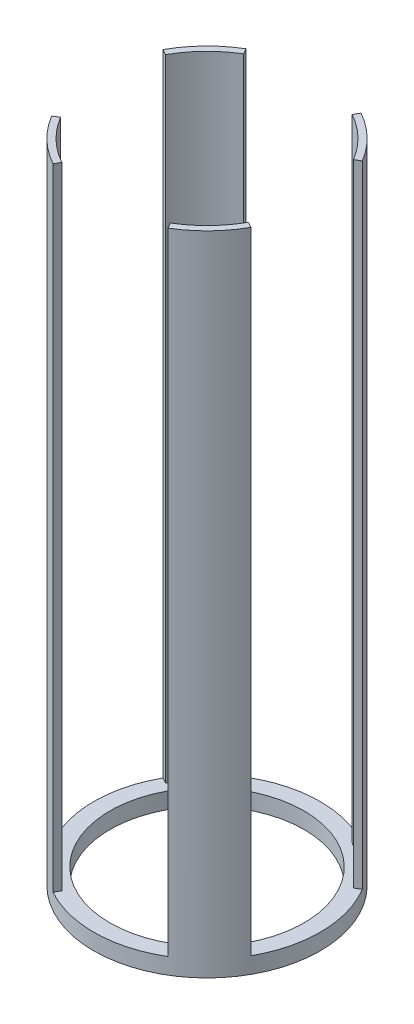
from build123d import *

# Parameters (mm, degrees)
SKETCH2_R               = 88.9
SKETCH2_R_2             = 83.82
BOSS_EXTRUDE1_DEPTH     = 254
CUT_EXTRUDE1_DEPTH      = 255
CUT_EXTRUDE1_DEPTH_BACK = 255
SKETCH4_R               = 88.9
SKETCH4_R_2             = 76.2
BOSS_EXTRUDE2_DEPTH     = 12.7


with BuildPart() as part:
    # Sketch2 → Boss-Extrude1 (new body, symmetric)
    with BuildSketch(Plane(origin=(0, 0, 0), x_dir=(1, 0, 0), z_dir=(0, 1, 0))):
        Circle(SKETCH2_R)
        Circle(SKETCH2_R_2, mode=Mode.SUBTRACT)
    extrude(amount=BOSS_EXTRUDE1_DEPTH, both=True)

    # Sketch3 → Cut-Extrude1 (cut, two sides)
    with BuildSketch(Plane(origin=(0, 0, 0), x_dir=(1, 0, 0), z_dir=(0, 1, 0))) as cut_extrude1_sk:
        Polygon((169.661755759, -94.300371224), (0, 0), (169.661755759, 101.677593364), align=None)
        Polygon((0, 0), (53.900027233, 96.974944394), (-58.116685864, 96.974944394), align=None)
        Polygon((-123.741299607, 68.777140945), (-123.741299607, -74.157652604), (0, 0), align=None)
        Polygon((-65.840936026, -118.45858783), (0, 0), (70.991745134, -118.45858783), align=None)
    extrude(amount=CUT_EXTRUDE1_DEPTH, mode=Mode.SUBTRACT)
    extrude(cut_extrude1_sk.sketch, amount=-CUT_EXTRUDE1_DEPTH_BACK, mode=Mode.SUBTRACT)

    # Sketch4 → Boss-Extrude2 (add)
    with BuildSketch(Plane.XZ.offset(254)):
        Circle(SKETCH4_R)
        Circle(SKETCH4_R_2, mode=Mode.SUBTRACT)
    extrude(amount=-BOSS_EXTRUDE2_DEPTH)


solid = part.part
